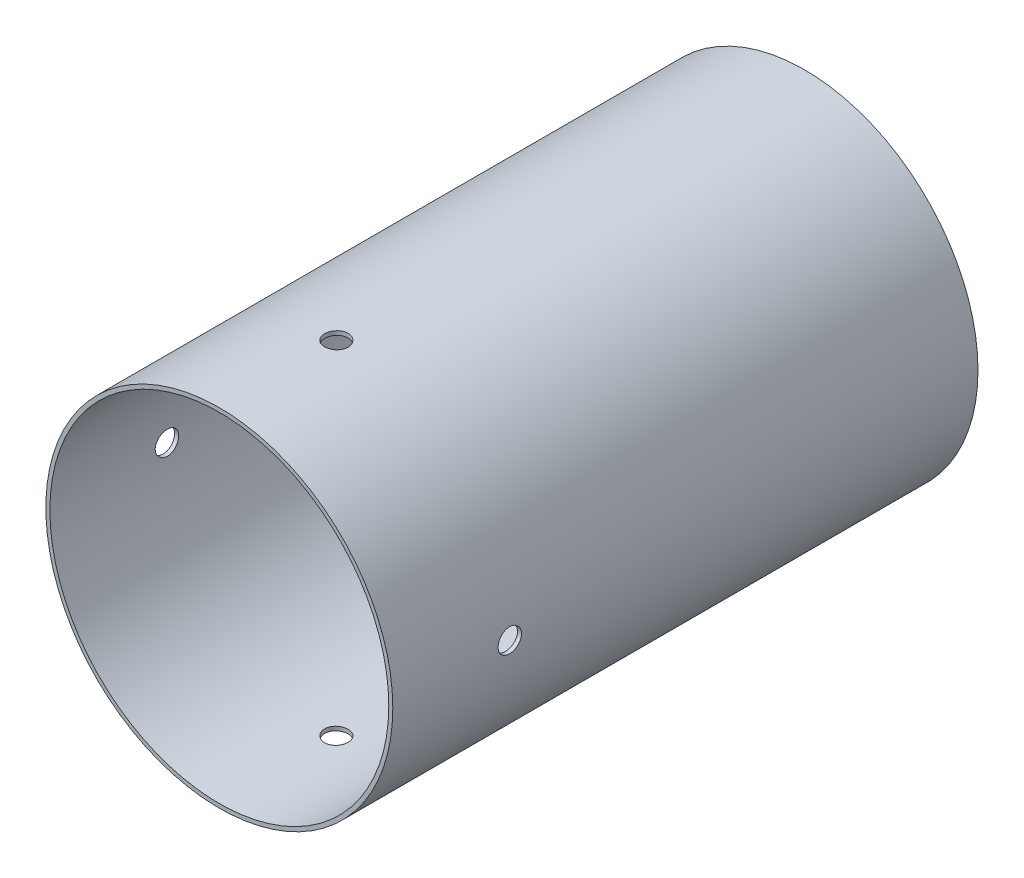
from build123d import *

# Parameters (mm, degrees)
SKETCH_1_R               = 148.209
SKETCH_1_R_2             = 144.78
EXTRUDE_1_DEPTH          = 500
SKETCH_2_W               = 10
SKETCH_2_H               = 30
PATTERN_CIRCULAR_1_COUNT = 4


with BuildPart() as part:
    # 草圖1 → 填料-伸長1 (new body)
    with BuildSketch(Plane.XY):
        Circle(SKETCH_1_R)
        Circle(SKETCH_1_R_2, mode=Mode.SUBTRACT)
    extrude(amount=EXTRUDE_1_DEPTH)

    # 草圖2 → 除料-旋轉1 (revolve, cut)
    with BuildSketch(Plane(origin=(0, 0, 0), x_dir=(0, 0, -1), z_dir=(1, 0, 0))):
        with Locations((-405, 148.209)):
            Rectangle(SKETCH_2_W, SKETCH_2_H)
    cut_revolve_1 = revolve(axis=Axis((0, 133.209, 400), (0, 1, 0)), mode=Mode.SUBTRACT)

    # 環狀複製排列1: 除料-旋轉1 ×4 about axis
    pattern_circular_1_axis = Axis((0, 0, 500), (0, 0, -1))
    for i in range(1, PATTERN_CIRCULAR_1_COUNT):
        add(cut_revolve_1.rotate(pattern_circular_1_axis, i * 360 / PATTERN_CIRCULAR_1_COUNT), mode=Mode.SUBTRACT)


solid = part.part
